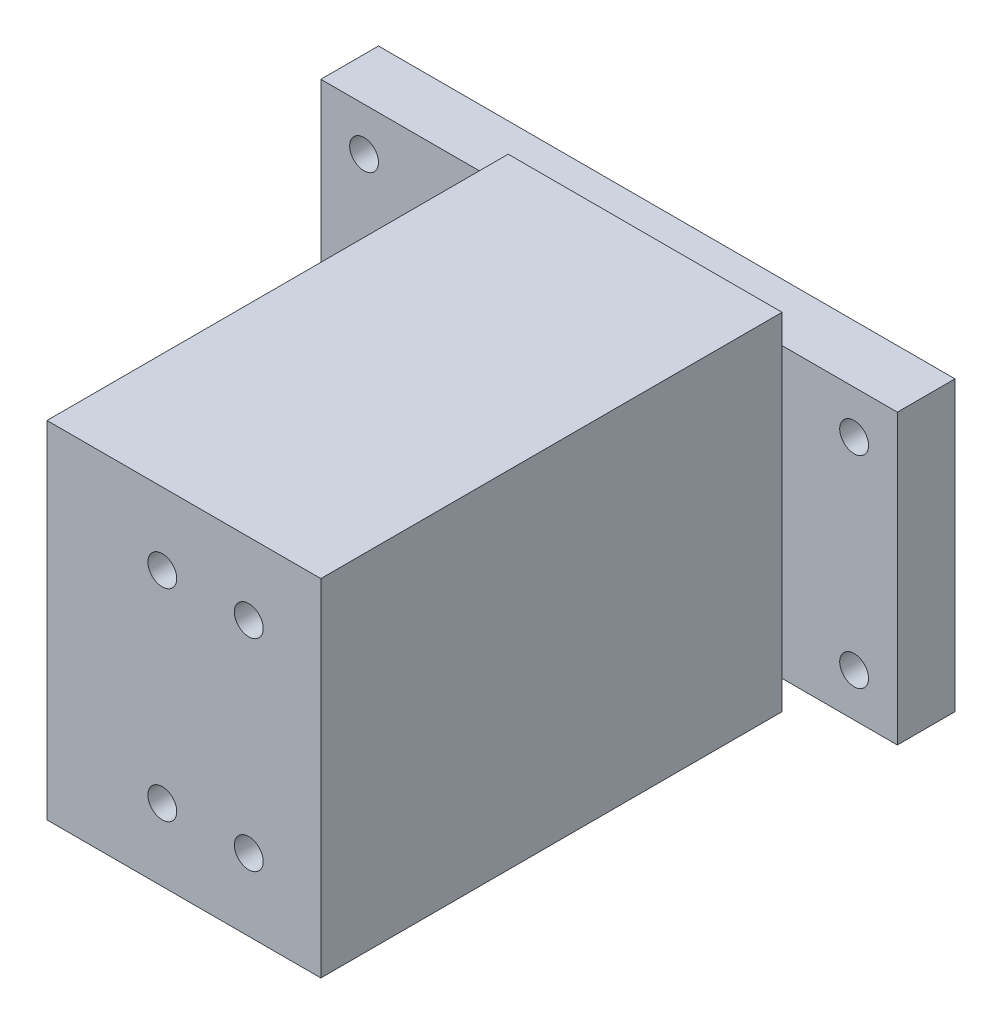
from build123d import *

# Parameters (mm, degrees)
SKETCH1_W           = 100
SKETCH1_H           = 50
SKETCH1_R           = 2.5
BOSS_EXTRUDE1_DEPTH = 10
SKETCH2_W           = 47.5
SKETCH2_H           = 60
BOSS_EXTRUDE2_DEPTH = 80
SKETCH3_R           = 2.5
CUT_EXTRUDE1_DEPTH  = 10
SKETCH9_R           = 2.5
CUT_EXTRUDE18_DEPTH = 10


with BuildPart() as part:
    # Sketch1 → Boss-Extrude1 (new body)
    with BuildSketch(Plane.XY):
        Rectangle(SKETCH1_W, SKETCH1_H)
        with Locations((-42.5, 17.5)):
            Circle(SKETCH1_R, mode=Mode.SUBTRACT)
        with Locations((42.5, 17.5)):
            Circle(SKETCH1_R, mode=Mode.SUBTRACT)
        with Locations((42.5, -17.5)):
            Circle(SKETCH1_R, mode=Mode.SUBTRACT)
        with Locations((-42.5, -17.5)):
            Circle(SKETCH1_R, mode=Mode.SUBTRACT)
    extrude(amount=BOSS_EXTRUDE1_DEPTH)

    # Sketch2 → Boss-Extrude2 (add)
    with BuildSketch(Plane.XY.offset(10)):
        with Locations((6.25, 0)):
            Rectangle(SKETCH2_W, SKETCH2_H)
    extrude(amount=BOSS_EXTRUDE2_DEPTH)

    # Sketch3 → Cut-Extrude1 (cut)
    with BuildSketch(Plane.XY.offset(90)):
        with Locations((17.5, 17.5)):
            Circle(SKETCH3_R)
        with Locations((2.5, 17.5)):
            Circle(SKETCH3_R)
        with Locations((2.5, -17.5)):
            Circle(SKETCH3_R)
        with Locations((17.5, -17.5)):
            Circle(SKETCH3_R)
    extrude(amount=-CUT_EXTRUDE1_DEPTH, mode=Mode.SUBTRACT)

    # Sketch9 → Cut-Extrude18 (cut)
    with BuildSketch(Plane.ZY.offset(17.5)):
        with Locations((77.5, 15)):
            Circle(SKETCH9_R)
        with Locations((42.5, -20)):
            Circle(SKETCH9_R)
        with Locations((77.5, -20)):
            Circle(SKETCH9_R)
        with Locations((42.5, 15)):
            Circle(SKETCH9_R)
    extrude(amount=-CUT_EXTRUDE18_DEPTH, mode=Mode.SUBTRACT)


solid = part.part
